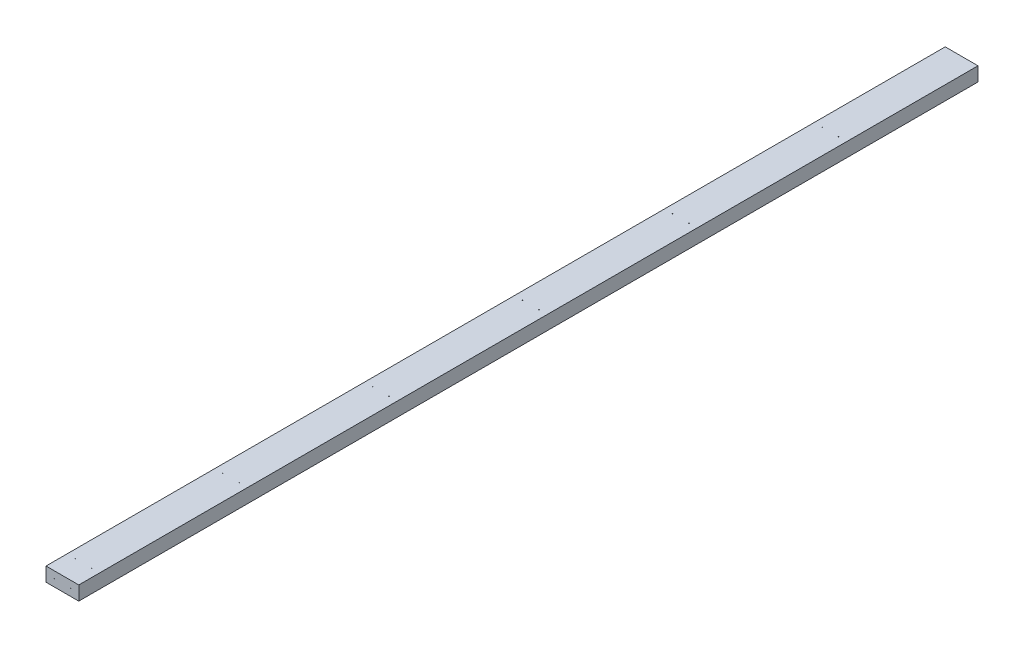
from build123d import *

# Parameters (mm, degrees)
SKETCH1_W           = 88.9
SKETCH1_H           = 38.1
SKETCH1_R           = 0.8763
BOSS_EXTRUDE1_DEPTH = 2438.4
SKETCH3_R           = 0.8763
CUT_EXTRUDE1_DEPTH  = 38.1
LPATTERN1_COUNT     = 5
LPATTERN1_PITCH     = 406.4
SKETCH4_R           = 0.8763
CUT_EXTRUDE2_DEPTH  = 38.1


with BuildPart() as part:
    # Sketch1 → Boss-Extrude1 (new body)
    with BuildSketch(Plane.XY):
        with Locations((44.45, 19.05)):
            Rectangle(SKETCH1_W, SKETCH1_H)
        with Locations((22.225, 19.05)):
            Circle(SKETCH1_R, mode=Mode.SUBTRACT)
        with Locations((66.675, 19.05)):
            Circle(SKETCH1_R, mode=Mode.SUBTRACT)
    extrude(amount=BOSS_EXTRUDE1_DEPTH)

    # Sketch3 → Cut-Extrude1 (cut)
    with BuildSketch(Plane.XZ):
        with Locations((22.225, 355.6)):
            Circle(SKETCH3_R)
        with Locations((66.675, 355.6)):
            Circle(SKETCH3_R)
    cut_extrude1 = extrude(amount=-CUT_EXTRUDE1_DEPTH, mode=Mode.SUBTRACT)

    # LPattern1: Cut-Extrude1 ×5
    with Locations(*[(0, 0, i * LPATTERN1_PITCH) for i in range(1, LPATTERN1_COUNT)]):
        add(cut_extrude1, mode=Mode.SUBTRACT)

    # Sketch4 → Cut-Extrude2 (cut)
    with BuildSketch(Plane.XZ):
        with Locations((22.225, 2381.25)):
            Circle(SKETCH4_R)
        with Locations((66.675, 2381.25)):
            Circle(SKETCH4_R)
    extrude(amount=-CUT_EXTRUDE2_DEPTH, mode=Mode.SUBTRACT)


solid = part.part
